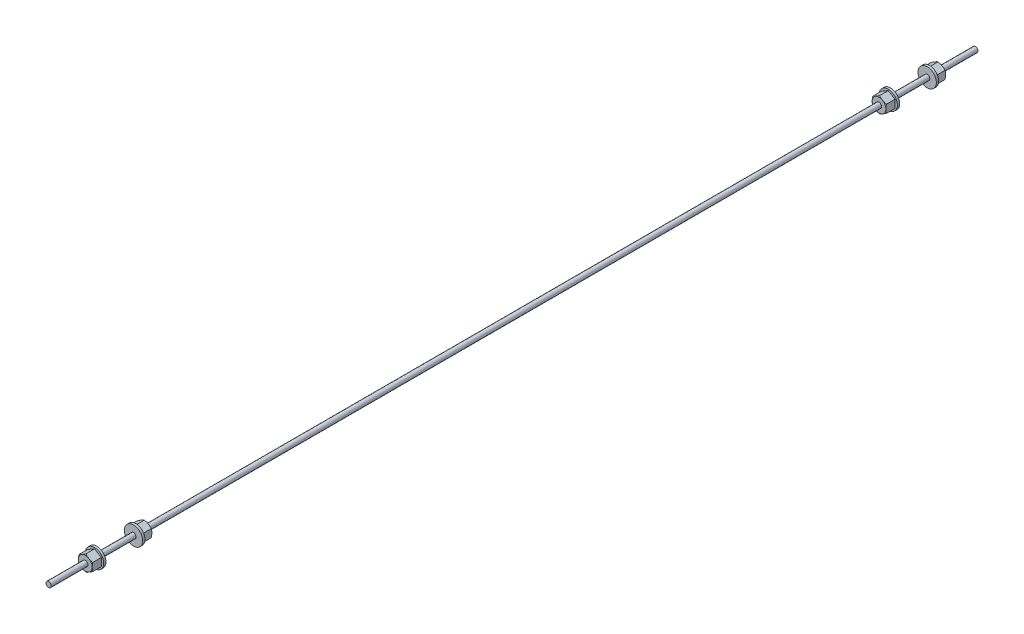
from build123d import *

# Parameters (mm, degrees)
EXTRUDE1_DEPTH          = 7.9375
SKETCH13_R              = 6.35
EXTRUDE3_DEPTH          = 1.5875
SKETCH2_OUTSIDE_W       = 63.61
SKETCH2_OUTSIDE_H       = 63.61
SKETCH2_OUTSIDE_R       = 4.7625
CUT_EXTRUDE1_DEPTH      = 12.985362166
CUT_EXTRUDE1_DRAFT      = -60
SKETCH14_R              = 1.8161
BOSS_EXTRUDE1_DEPTH     = 12.7
MIRROR1_COPY_1_SKETCH_W = 63.61
MIRROR1_COPY_1_SKETCH_H = 63.61
MIRROR1_COPY_1_SKETCH_R = 4.7625
MIRROR1_COPY_1_DEPTH    = 12.985362166
MIRROR1_COPY_1_DRAFT    = -60
SKETCH15_R              = 1.8161
BOSS_EXTRUDE2_DEPTH     = 254
MIRROR2_COPY_1_SKETCH_W = 63.61
MIRROR2_COPY_1_SKETCH_H = 63.61
MIRROR2_COPY_1_SKETCH_R = 4.7625
MIRROR2_COPY_1_DEPTH    = 12.985362166
MIRROR2_COPY_1_DRAFT    = -60
MIRROR2_COPY_2_DEPTH    = 7.9375
MIRROR2_COPY_3_SKETCH_R = 6.35
MIRROR2_COPY_3_DEPTH    = 1.5875
MIRROR2_COPY_4_SKETCH_R = 1.8161
MIRROR2_COPY_4_DEPTH    = 12.7
MIRROR2_COPY_5_SKETCH_W = 63.61
MIRROR2_COPY_5_SKETCH_H = 63.61
MIRROR2_COPY_5_SKETCH_R = 4.7625
MIRROR2_COPY_5_DEPTH    = 12.985362166
MIRROR2_COPY_5_DRAFT    = -60
SKETCH16_R              = 1.8161
BOSS_EXTRUDE3_DEPTH     = 25.4
SKETCH4_R               = 1.8161
BOSS_EXTRUDE4_DEPTH     = 25.4


with BuildPart() as part:
    # Sketch1 → Extrude1 (new body)
    with BuildSketch(Plane.XY):
        Polygon((0, 5.499261314), (-4.7625, 2.749630657), (-4.7625, -2.749630657), (0, -5.499261314), (4.7625, -2.749630657), (4.7625, 2.749630657), align=None)
    extrude1 = extrude(amount=-EXTRUDE1_DEPTH)

    # Sketch13 → Extrude3 (add)
    with BuildSketch(Plane(origin=(0, 0, -7.9375), x_dir=(-1, 0, 0), z_dir=(0, 0, -1))):
        Circle(SKETCH13_R)
    extrude3 = extrude(amount=-EXTRUDE3_DEPTH)


with BuildPart() as cut_extrude1_tool:
    # Sketch2 outside → Cut-Extrude1 (with draft: the straight prism first)
    with BuildSketch(Plane.XY):
        Rectangle(SKETCH2_OUTSIDE_W, SKETCH2_OUTSIDE_H)
        Circle(SKETCH2_OUTSIDE_R, mode=Mode.SUBTRACT)
    extrude(amount=-CUT_EXTRUDE1_DEPTH)
    # Cut-Extrude1: the draft: its side faces are tilted about the plane it starts from
    cut_extrude1_sides = [cut_extrude1_tool.faces().sort_by_distance(p)[0] for p in [
        (0, -31.805, -6.492681083),
        (31.805, 0, -6.492681083),
        (0, 31.805, -6.492681083),
        (-31.805, 0, -6.492681083),
        (-4.7625, 0, -6.492681083),
    ]]
    draft(cut_extrude1_sides, Plane.XY, CUT_EXTRUDE1_DRAFT)


with BuildPart() as part_1:
    add(part.part)

    # Cut-Extrude1: cut by cut_extrude1_tool
    add(cut_extrude1_tool.part, mode=Mode.SUBTRACT)

    # Sketch14 → Boss-Extrude1 (add)
    with BuildSketch(Plane(origin=(0, 0, -7.9375), x_dir=(-1, 0, 0), z_dir=(0, 0, -1))):
        Circle(SKETCH14_R)
    boss_extrude1 = extrude(amount=BOSS_EXTRUDE1_DEPTH)

    # Mirror1: Extrude1, Extrude3, Boss-Extrude1 across plane
    add(extrude1.mirror(Plane(origin=(0, 0, -20.6375), x_dir=(1, 0, 0), z_dir=(0, 0, -1))))
    add(extrude3.mirror(Plane(origin=(0, 0, -20.6375), x_dir=(1, 0, 0), z_dir=(0, 0, -1))))
    add(boss_extrude1.mirror(Plane(origin=(0, 0, -20.6375), x_dir=(1, 0, 0), z_dir=(0, 0, -1))))


with BuildPart() as mirror1_copy_1_tool:
    # Mirror1 copy 1 sketch → Mirror1 copy 1 (with draft: the straight prism first)
    with BuildSketch(Plane(origin=(0, 0, -41.275), x_dir=(1, 0, 0), z_dir=(0, 0, -1))):
        Rectangle(MIRROR1_COPY_1_SKETCH_W, MIRROR1_COPY_1_SKETCH_H)
        Circle(MIRROR1_COPY_1_SKETCH_R, mode=Mode.SUBTRACT)
    extrude(amount=-MIRROR1_COPY_1_DEPTH)
    # Mirror1 copy 1: the draft: its side faces are tilted about the plane it starts from
    mirror1_copy_1_sides = [mirror1_copy_1_tool.faces().sort_by_distance(p)[0] for p in [
        (0, -31.805, -34.782318917),
        (31.805, 0, -34.782318917),
        (0, 31.805, -34.782318917),
        (-31.805, 0, -34.782318917),
        (-4.7625, 0, -34.782318917),
    ]]
    draft(mirror1_copy_1_sides, Plane(origin=(0, 0, -41.275), x_dir=(1, 0, 0), z_dir=(0, 0, -1)), MIRROR1_COPY_1_DRAFT)


with BuildPart() as part_2:
    add(part_1.part)

    # Mirror1 copy 1: cut by mirror1_copy_1_tool
    add(mirror1_copy_1_tool.part, mode=Mode.SUBTRACT)

    # Sketch15 → Boss-Extrude2 (add)
    with BuildSketch(Plane(origin=(0, 0, -41.275), x_dir=(-1, 0, 0), z_dir=(0, 0, -1))):
        Circle(SKETCH15_R)
    boss_extrude2 = extrude(amount=BOSS_EXTRUDE2_DEPTH)

    # Mirror2: Extrude1, Extrude3, Boss-Extrude1, Boss-Extrude2 across plane
    add(extrude1.mirror(Plane(origin=(0, 0, -295.275), x_dir=(1, 0, 0), z_dir=(0, 0, -1))))
    add(extrude3.mirror(Plane(origin=(0, 0, -295.275), x_dir=(1, 0, 0), z_dir=(0, 0, -1))))
    add(boss_extrude1.mirror(Plane(origin=(0, 0, -295.275), x_dir=(1, 0, 0), z_dir=(0, 0, -1))))
    add(boss_extrude2.mirror(Plane(origin=(0, 0, -295.275), x_dir=(1, 0, 0), z_dir=(0, 0, -1))))


with BuildPart() as mirror2_copy_1_tool:
    # Mirror2 copy 1 sketch → Mirror2 copy 1 (with draft: the straight prism first)
    with BuildSketch(Plane(origin=(0, 0, -590.55), x_dir=(1, 0, 0), z_dir=(0, 0, -1))):
        Rectangle(MIRROR2_COPY_1_SKETCH_W, MIRROR2_COPY_1_SKETCH_H)
        Circle(MIRROR2_COPY_1_SKETCH_R, mode=Mode.SUBTRACT)
    extrude(amount=-MIRROR2_COPY_1_DEPTH)
    # Mirror2 copy 1: the draft: its side faces are tilted about the plane it starts from
    mirror2_copy_1_sides = [mirror2_copy_1_tool.faces().sort_by_distance(p)[0] for p in [
        (0, -31.805, -584.057318917),
        (31.805, 0, -584.057318917),
        (0, 31.805, -584.057318917),
        (-31.805, 0, -584.057318917),
        (-4.7625, 0, -584.057318917),
    ]]
    draft(mirror2_copy_1_sides, Plane(origin=(0, 0, -590.55), x_dir=(1, 0, 0), z_dir=(0, 0, -1)), MIRROR2_COPY_1_DRAFT)


with BuildPart() as part_3:
    add(part_2.part)

    # Mirror2 copy 1: cut by mirror2_copy_1_tool
    add(mirror2_copy_1_tool.part, mode=Mode.SUBTRACT)

    # Mirror2 copy 2 sketch → Mirror2 copy 2 (add)
    with BuildSketch(Plane.XY.offset(-549.275)):
        Polygon((0, 5.499261314), (-4.7625, 2.749630657), (-4.7625, -2.749630657), (0, -5.499261314), (4.7625, -2.749630657), (4.7625, 2.749630657), align=None)
    extrude(amount=-MIRROR2_COPY_2_DEPTH)

    # Mirror2 copy 3 sketch → Mirror2 copy 3 (add)
    with BuildSketch(Plane(origin=(0, 0, -557.2125), x_dir=(-1, 0, 0), z_dir=(0, 0, -1))):
        Circle(MIRROR2_COPY_3_SKETCH_R)
    extrude(amount=-MIRROR2_COPY_3_DEPTH)

    # Mirror2 copy 4 sketch → Mirror2 copy 4 (add)
    with BuildSketch(Plane(origin=(0, 0, -557.2125), x_dir=(-1, 0, 0), z_dir=(0, 0, -1))):
        Circle(MIRROR2_COPY_4_SKETCH_R)
    extrude(amount=MIRROR2_COPY_4_DEPTH)


with BuildPart() as mirror2_copy_5_tool:
    # Mirror2 copy 5 sketch → Mirror2 copy 5 (with draft: the straight prism first)
    with BuildSketch(Plane.XY.offset(-549.275)):
        Rectangle(MIRROR2_COPY_5_SKETCH_W, MIRROR2_COPY_5_SKETCH_H)
        Circle(MIRROR2_COPY_5_SKETCH_R, mode=Mode.SUBTRACT)
    extrude(amount=-MIRROR2_COPY_5_DEPTH)
    # Mirror2 copy 5: the draft: its side faces are tilted about the plane it starts from
    mirror2_copy_5_sides = [mirror2_copy_5_tool.faces().sort_by_distance(p)[0] for p in [
        (0, -31.805, -555.767681083),
        (31.805, 0, -555.767681083),
        (0, 31.805, -555.767681083),
        (-31.805, 0, -555.767681083),
        (-4.7625, 0, -555.767681083),
    ]]
    draft(mirror2_copy_5_sides, Plane.XY.offset(-549.275), MIRROR2_COPY_5_DRAFT)


with BuildPart() as part_4:
    add(part_3.part)

    # Mirror2 copy 5: cut by mirror2_copy_5_tool
    add(mirror2_copy_5_tool.part, mode=Mode.SUBTRACT)

    # Sketch16 → Boss-Extrude3 (add)
    with BuildSketch(Plane(origin=(0, 0, -590.55), x_dir=(-1, 0, 0), z_dir=(0, 0, -1))):
        Circle(SKETCH16_R)
    extrude(amount=BOSS_EXTRUDE3_DEPTH)

    # Sketch4 → Boss-Extrude4 (add)
    with BuildSketch(Plane.XY):
        with Locations(Location((0, 0, 0), (0, 0, 180))):
            Circle(SKETCH4_R)
    extrude(amount=BOSS_EXTRUDE4_DEPTH)


solid = part_4.part
